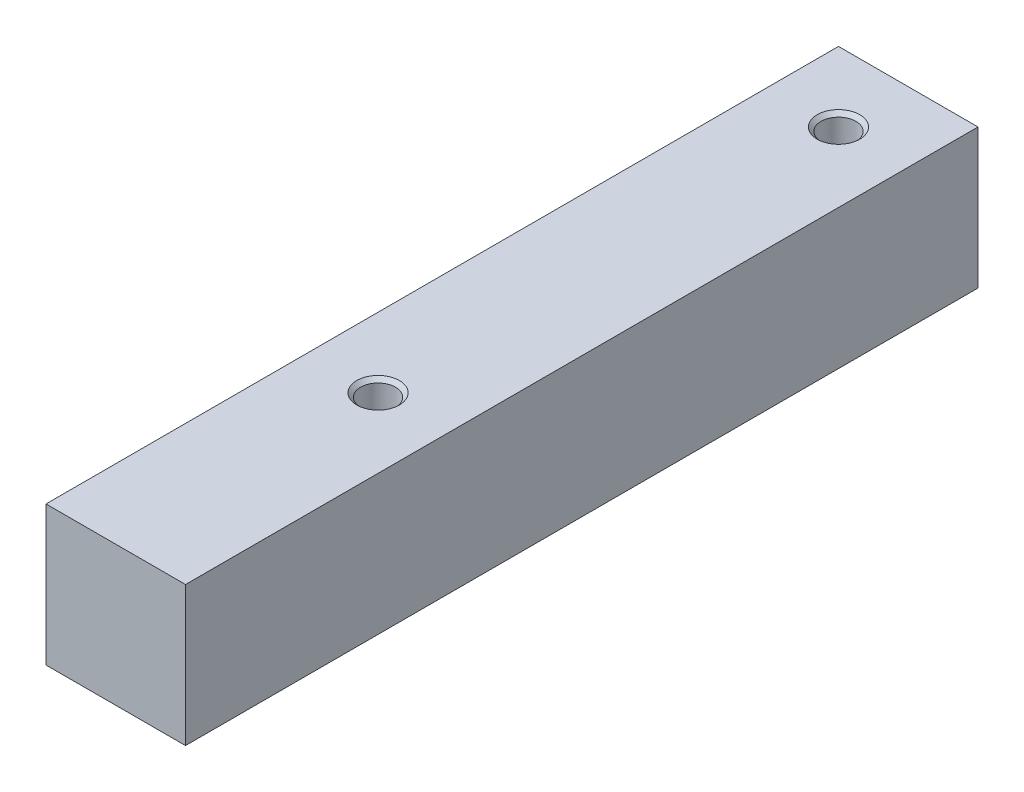
from build123d import *

# Parameters (mm, degrees)
ESQUISSE1_W                     = 10
ESQUISSE1_H                     = 10
BOSS_EXTRU_1_DEPTH              = 54.8
BOSS_EXTRU_1_DEPTH_BACK         = 2
TROU_TARAUD_M3X0_51_D           = 2.5
TROU_TARAUD_M3X0_51_CSINK_D     = 3.05
TROU_TARAUD_M3X0_51_CSINK_ANGLE = 90


with BuildPart() as part:
    # Esquisse1 → Boss.-Extru.1 (new body, two sides)
    with BuildSketch(Plane.XY) as boss_extru_1_sk:
        Rectangle(ESQUISSE1_W, ESQUISSE1_H)
    extrude(amount=BOSS_EXTRU_1_DEPTH)
    extrude(boss_extru_1_sk.sketch, amount=-BOSS_EXTRU_1_DEPTH_BACK)

    # Trou taraud_ M3x0.51 (through all)
    with Locations(Plane(origin=(0, 5, 0), x_dir=(1, 0, 0), z_dir=(0, 1, 0))):
        with Locations((0, -36), (0, -3)):
            CounterSinkHole(TROU_TARAUD_M3X0_51_D / 2, TROU_TARAUD_M3X0_51_CSINK_D / 2, counter_sink_angle=TROU_TARAUD_M3X0_51_CSINK_ANGLE)


solid = part.part
